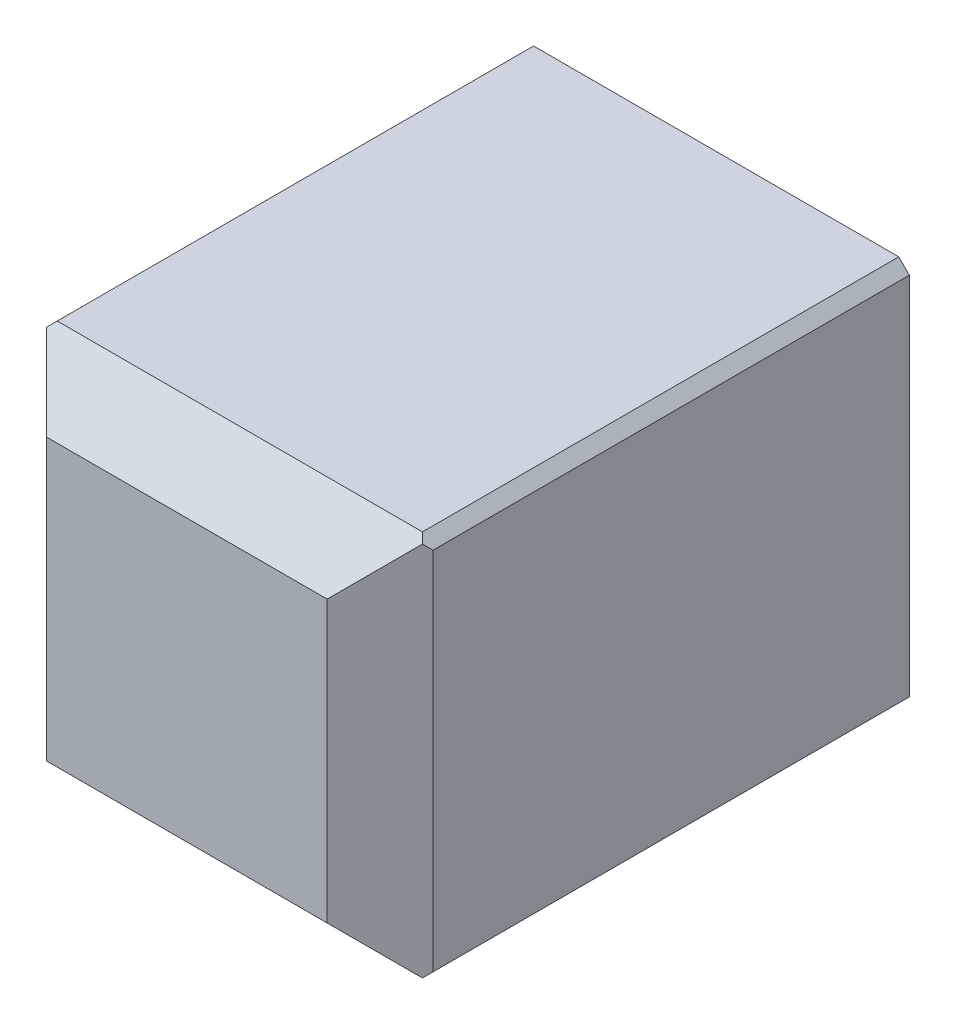
from build123d import *

# Parameters (mm, degrees)
SKETCH1_W           = 7.3
SKETCH1_H           = 7.3
SKETCH1_W_2         = 3.3
SKETCH1_H_2         = 3.3
BOSS_EXTRUDE1_DEPTH = 8
SKETCH3_W           = 7.3
SKETCH3_H           = 7.3
BOSS_EXTRUDE2_DEPTH = 2
CHAMFER1_SIZE       = 1
CHAMFER2_SIZE       = 0.2


with BuildPart() as part:
    # Sketch1 → Boss-Extrude1 (new body)
    with BuildSketch(Plane.XY):
        with Locations((1.65, 1.65)):
            Rectangle(SKETCH1_W, SKETCH1_H)
        with Locations((1.65, 1.65)):
            Rectangle(SKETCH1_W_2, SKETCH1_H_2, mode=Mode.SUBTRACT)
    extrude(amount=BOSS_EXTRUDE1_DEPTH)

    # Sketch3 → Boss-Extrude2 (add)
    with BuildSketch(Plane.XY.offset(8)):
        with Locations((1.65, 1.65)):
            Rectangle(SKETCH3_W, SKETCH3_H)
    extrude(amount=BOSS_EXTRUDE2_DEPTH)

    # Chamfer1
    chamfer1_edges = [part.edges().sort_by_distance(p)[0] for p in [
        (-2, 1.65, 10),
        (1.65, -2, 10),
        (5.3, 1.65, 10),
        (1.65, 5.3, 10),
    ]]
    chamfer(chamfer1_edges, length=CHAMFER1_SIZE)

    # Chamfer2
    chamfer2_edges = [part.edges().sort_by_distance(p)[0] for p in [
        (-2, 5.3, 4.5),
        (5.3, 5.3, 4.5),
        (5.3, -2, 4.5),
        (-2, -2, 4.5),
    ]]
    chamfer(chamfer2_edges, length=CHAMFER2_SIZE)


solid = part.part
